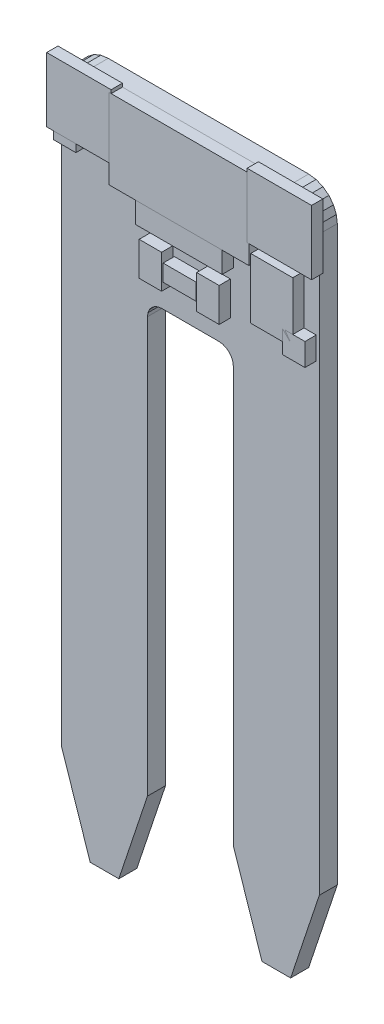
from build123d import *

# Parameters (mm, degrees)
BOARD_DEPTH                             = 1.6
SKETCH2_W                               = 2
SKETCH2_H                               = 2
FIDUCIAL_1X2_1_DEPTH                    = 1
SKETCH3_W                               = 2
SKETCH3_H                               = 2
FIDUCIAL_1X2_2_DEPTH                    = 1
SKETCH5_W                               = 7.6835
SKETCH5_H                               = 5.715
MOLEX_1X3_1_DEPTH                       = 1
SKETCH6_W                               = 12.4
SKETCH6_H                               = 7.1016
SCREWTERMINAL_3_5MM_3_LOCK_007S_1_DEPTH = 1
SKETCH7_W                               = 11.33
SKETCH7_H                               = 5.19
SFE_LOGO_NAME_FLAME_1_1_DEPTH           = 1
SKETCH8_W                               = 2.9776
SKETCH8_H                               = 2.6708
OSHW_LOGO_S_1_DEPTH                     = 1
SKETCH9_W                               = 2.921
SKETCH9_H                               = 1.4732
SOT23_3_1_DEPTH                         = 1
SKETCH10_W                              = 1.9914
SKETCH10_H                              = 2.9968
F_0603_RES_1_DEPTH                      = 1
SKETCH11_W                              = 1.9914
SKETCH11_H                              = 2.9968
F_0603_RES_2_DEPTH                      = 1
SKETCH12_W                              = 5.715
SKETCH12_H                              = 5.715
STAND_OFF_1_DEPTH                       = 1
SKETCH13_W                              = 5.715
SKETCH13_H                              = 5.715
STAND_OFF_2_DEPTH                       = 1
SKETCH14_W                              = 3.73
SKETCH14_H                              = 5.36
SFE_LOGO_FLAME_2_1_DEPTH                = 1


with BuildPart() as part:
    # Sketch1 → BOARD (new body)
    with BuildSketch(Plane.XY):
        Polygon((2.54, 60.96), (1.8826, 60.873452), (1.27, 60.619705), (0.743949, 60.216051), (0.340295, 59.69), (0.086548, 59.0774), (0, 58.42), (0, 7.62), (2.54, 0), (5.08, 0), (7.62, 7.62), (7.62, 44.45), (7.663274, 44.7787), (7.790148, 45.085), (7.991974, 45.348026), (8.255, 45.549852), (8.5613, 45.676726), (8.89, 45.72), (13.97, 45.72), (14.2987, 45.676726), (14.605, 45.549852), (14.868026, 45.348026), (15.069852, 45.085), (15.196726, 44.7787), (15.24, 44.45), (15.24, 7.62), (17.78, 0), (20.32, 0), (22.86, 7.62), (22.86, 58.42), (22.773452, 59.0774), (22.519705, 59.69), (22.116051, 60.216051), (21.59, 60.619705), (20.9774, 60.873452), (20.32, 60.96), align=None)
    extrude(amount=BOARD_DEPTH)


with BuildPart() as body_2:
    # Sketch2 → FIDUCIAL-1X2-1 (new body)
    with BuildSketch(Plane.XY.offset(1.6)):
        with Locations((1.27, 55.88)):
            Rectangle(SKETCH2_W, SKETCH2_H)
    extrude(amount=FIDUCIAL_1X2_1_DEPTH)


with BuildPart() as body_3:
    # Sketch3 → FIDUCIAL-1X2-2 (new body)
    with BuildSketch(Plane.XY.offset(1.6)):
        with Locations((21.59, 49.53)):
            Rectangle(SKETCH3_W, SKETCH3_H)
    extrude(amount=FIDUCIAL_1X2_2_DEPTH)


with BuildPart() as body_4:
    # Sketch5 → MOLEX-1X3-1 (new body)
    with BuildSketch(Plane.XY.offset(1.6)):
        with Locations((11.39825, 54.864)):
            Rectangle(SKETCH5_W, SKETCH5_H)
    extrude(amount=MOLEX_1X3_1_DEPTH)


with BuildPart() as body_5:
    # Sketch6 → SCREWTERMINAL-3_5MM-3_LOCK_007S-1 (new body)
    with BuildSketch(Plane.XY.offset(1.6)):
        with Locations((11.4098, 57.4278)):
            Rectangle(SKETCH6_W, SKETCH6_H)
    extrude(amount=SCREWTERMINAL_3_5MM_3_LOCK_007S_1_DEPTH)


with BuildPart() as body_6:
    # Sketch7 → SFE_LOGO_NAME_FLAME__1-1 (new body)
    with BuildSketch(Plane.XY):
        with Locations((12.115, 50.855)):
            Rectangle(SKETCH7_W, SKETCH7_H)
    extrude(amount=-SFE_LOGO_NAME_FLAME_1_1_DEPTH)


with BuildPart() as body_7:
    # Sketch8 → OSHW-LOGO-S-1 (new body)
    with BuildSketch(Plane.XY):
        with Locations((20.32, 54.7634)):
            Rectangle(SKETCH8_W, SKETCH8_H)
    extrude(amount=-OSHW_LOGO_S_1_DEPTH)


with BuildPart() as body_8:
    # Sketch9 → SOT23-3-1 (new body)
    with BuildSketch(Plane.XY.offset(1.6)):
        with Locations((11.4681, 49.53)):
            Rectangle(SKETCH9_W, SKETCH9_H)
    extrude(amount=SOT23_3_1_DEPTH)


with BuildPart() as body_9:
    # Sketch10 → 0603-RES-1 (new body)
    with BuildSketch(Plane.XY.offset(1.6)):
        with Locations((13.9827, 49.53)):
            Rectangle(SKETCH10_W, SKETCH10_H)
    extrude(amount=F_0603_RES_1_DEPTH)


with BuildPart() as body_10:
    # Sketch11 → 0603-RES-2 (new body)
    with BuildSketch(Plane.XY.offset(1.6)):
        with Locations((8.8773, 49.53)):
            Rectangle(SKETCH11_W, SKETCH11_H)
    extrude(amount=F_0603_RES_2_DEPTH)


with BuildPart() as body_11:
    # Sketch12 → STAND-OFF-1 (new body)
    with BuildSketch(Plane.XY.offset(1.6)):
        with Locations((2.54, 58.42)):
            Rectangle(SKETCH12_W, SKETCH12_H)
    extrude(amount=STAND_OFF_1_DEPTH)


with BuildPart() as body_12:
    # Sketch13 → STAND-OFF-2 (new body)
    with BuildSketch(Plane.XY.offset(1.6)):
        with Locations((20.32, 58.42)):
            Rectangle(SKETCH13_W, SKETCH13_H)
    extrude(amount=STAND_OFF_2_DEPTH)


with BuildPart() as body_13:
    # Sketch14 → SFE_LOGO_FLAME__2-1 (new body)
    with BuildSketch(Plane.XY.offset(1.6)):
        with Locations((19.645, 52.21)):
            Rectangle(SKETCH14_W, SKETCH14_H)
    extrude(amount=SFE_LOGO_FLAME_2_1_DEPTH)


solid = Compound([part.part, body_2.part, body_3.part, body_4.part, body_5.part, body_6.part, body_7.part, body_8.part, body_9.part, body_10.part, body_11.part, body_12.part, body_13.part])
